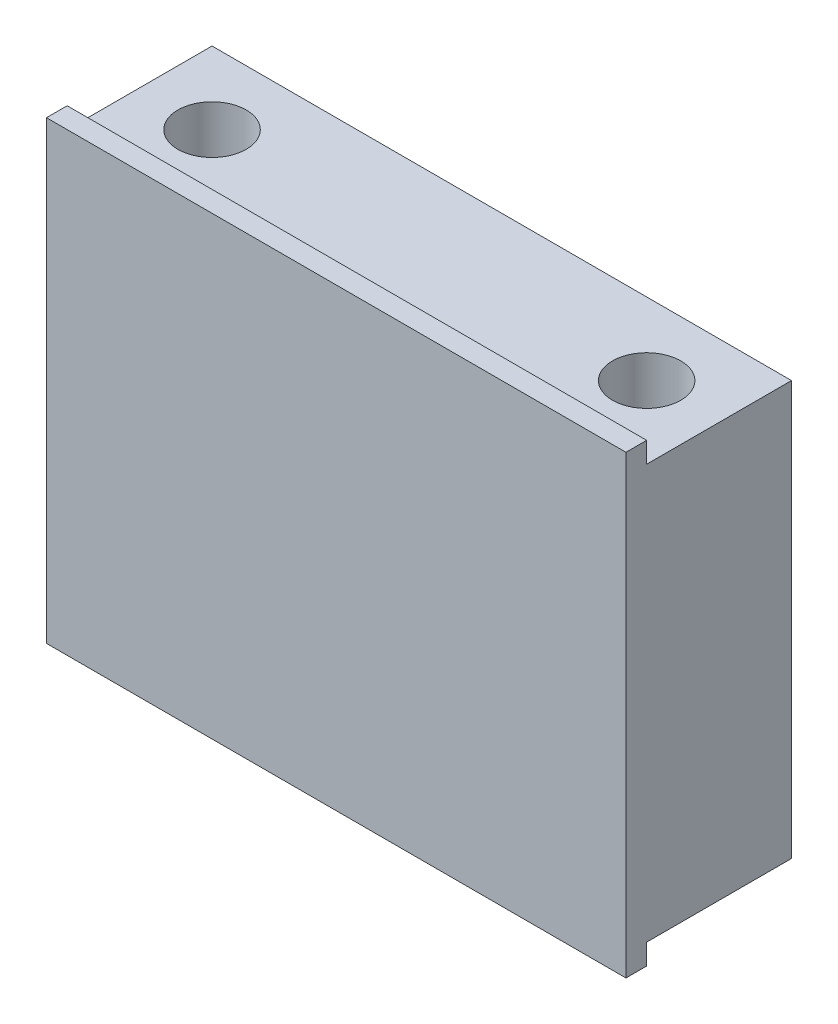
from build123d import *

# Parameters (mm, degrees)
SKETCH5_W                = 28
SKETCH5_H                = 20
BOSS_EXTRUDE2_DEPTH      = 4.5
BOSS_EXTRUDE2_DEPTH_BACK = 3.5
SKETCH9_W                = 28
SKETCH9_H                = 1
BOSS_EXTRUDE3_DEPTH      = 1
M4X0_7_TAPPED_HOLE2_D    = 3.3
CUT_EXTRUDE3_DEPTH       = 0.5


with BuildPart() as part:
    # Sketch5 → Boss-Extrude2 (new body, two sides)
    with BuildSketch(Plane.XY) as boss_extrude2_sk:
        Rectangle(SKETCH5_W, SKETCH5_H)
    extrude(amount=BOSS_EXTRUDE2_DEPTH)
    extrude(boss_extrude2_sk.sketch, amount=-BOSS_EXTRUDE2_DEPTH_BACK)

    # Sketch9 → Boss-Extrude3 (add)
    with BuildSketch(Plane(origin=(0, 10, 0), x_dir=(1, 0, 0), z_dir=(0, 1, 0))):
        with Locations((0, -4)):
            Rectangle(SKETCH9_W, SKETCH9_H)
    boss_extrude3 = extrude(amount=BOSS_EXTRUDE3_DEPTH)

    # Mirror2: Boss-Extrude3 across plane
    add(boss_extrude3.mirror(Plane.ZX))

    # M4x0.7 Tapped Hole2 (through all)
    with Locations(Plane(origin=(0, 10, 0), x_dir=(-1, 0, 0), z_dir=(0, 1, 0))):
        with Locations((10.5, 0), (-10.5, 0)):
            Hole(M4X0_7_TAPPED_HOLE2_D / 2)

    # Sketch18 → Cut-Extrude3 (cut)
    with BuildSketch(Plane.ZY.offset(14)):
        with BuildLine():
            Line((-1.358666808, -3.858598867), (-1.358666808, -3.175706239))
            add(Edge.make_bspline(
                [(-1.358666808, -3.175706239), (-1.358493825, -3.142277234), (-1.358158539, -3.077483501), (-1.352837806, -2.983271224), (-1.345764395, -2.894997594), (-1.333899128, -2.812818602), (-1.321596411, -2.736199521), (-1.303538968, -2.665918196), (-1.283593865, -2.601385933), (-1.252905616, -2.523895894), (-1.205246379, -2.435972827), (-1.134563201, -2.341471981), (-1.049819779, -2.25932608), (-0.953247965, -2.189477715), (-0.847008026, -2.133422916), (-0.733385749, -2.093382781), (-0.614292692, -2.067659474), (-0.53264339, -2.065047249), (-0.491379148, -2.063727072)],
                knots=[0, 0, 0, 0, 1.00128172, 1.940733171, 2.826250472, 3.653024905, 4.427672124, 5.149348099, 5.824709082, 6.450061444, 7.643590664, 8.808605388, 9.972104426, 11.165284501, 12.367876273, 13.557044126, 14.765369432, 16, 16, 16, 16], degree=3))
            add(Edge.make_bspline(
                [(-0.491379148, -2.063727072), (-0.452728292, -2.064826683), (-0.376775714, -2.066987522), (-0.265877874, -2.087398492), (-0.16042051, -2.119793619), (-0.060493879, -2.164564992), (0.032041876, -2.2222504), (0.116900105, -2.291365627), (0.190873633, -2.374407021), (0.232213446, -2.436655129), (0.253212198, -2.468274348)],
                knots=[0, 0, 0, 0, 1.044641374, 2.052818814, 3.038628718, 4.023282556, 5.005660861, 5.98021751, 6.974042014, 8, 8, 8, 8], degree=3))
            add(Edge.make_bspline(
                [(0.253212198, -2.468274348), (0.26848214, -2.42851776), (0.297697321, -2.352453558), (0.349268658, -2.247717736), (0.405563701, -2.157810249), (0.466090928, -2.0809748), (0.532295057, -2.015607722), (0.604713966, -1.958996053), (0.68328837, -1.910054162), (0.767729482, -1.868404951), (0.857321457, -1.835688977), (0.950970017, -1.811643189), (1.04831616, -1.797419583), (1.114377202, -1.795479265), (1.147843608, -1.794496303)],
                knots=[0, 0, 0, 0, 1.272586185, 2.434772614, 3.483318042, 4.437947805, 5.351807173, 6.25737843, 7.180033415, 8.1141739, 9.066731021, 10.025721652, 10.999834114, 12, 12, 12, 12], degree=3))
            add(Edge.make_bspline(
                [(1.147843608, -1.794496303), (1.18201062, -1.795472936), (1.249235171, -1.797394487), (1.34798832, -1.811577509), (1.442370565, -1.835575408), (1.532948895, -1.868687792), (1.619533397, -1.911606953), (1.701810406, -1.96459306), (1.779951098, -2.026902294), (1.854093382, -2.0973218), (1.921935902, -2.175798831), (1.98025759, -2.262285569), (2.03040593, -2.354412701), (2.07123492, -2.453357983), (2.102734459, -2.558868828), (2.124680974, -2.670886526), (2.139493315, -2.789226598), (2.140709493, -2.870436944), (2.141333192, -2.912084444)],
                knots=[0, 0, 0, 0, 0.978680899, 1.925582087, 2.851223405, 3.764209995, 4.683484765, 5.614004905, 6.562443559, 7.542772147, 8.539900013, 9.527881485, 10.525548727, 11.540192123, 12.58875426, 13.674701727, 14.807505862, 16, 16, 16, 16], degree=3))
            Line((2.141333192, -2.912084444), (2.141333192, -3.858598867))
            Line((2.141333192, -3.858598867), (-1.358666808, -3.858598867))
        make_face()
        with BuildLine():
            Line((-0.999692449, -3.544496303), (0.122102423, -3.544496303))
            Line((0.122102423, -3.544496303), (0.122102423, -3.333458643))
            add(Edge.make_bspline(
                [(0.122102423, -3.333458643), (0.1217025, -3.302609847), (0.120929767, -3.243003688), (0.118716249, -3.156683792), (0.112518208, -3.076558771), (0.106321937, -3.002766948), (0.096247378, -2.935424471), (0.084255162, -2.874680718), (0.07157256, -2.819581769), (0.050001794, -2.756043711), (0.018132793, -2.68396067), (-0.031373311, -2.607167438), (-0.090291826, -2.539153622), (-0.158911544, -2.48240852), (-0.233650484, -2.435556965), (-0.313852506, -2.402735978), (-0.39790365, -2.380855203), (-0.455716287, -2.37884849), (-0.485069052, -2.377829636)],
                knots=[0, 0, 0, 0, 1.156917035, 2.235399477, 3.236897345, 4.169954739, 5.01148057, 5.788325709, 6.491867502, 7.129259015, 8.302032419, 9.437271567, 10.542795419, 11.662606952, 12.764338259, 13.836858145, 14.901724648, 16, 16, 16, 16], degree=3))
            add(Edge.make_bspline(
                [(-0.485069052, -2.377829636), (-0.50449737, -2.378346947), (-0.542608137, -2.37936171), (-0.59834533, -2.387974533), (-0.650717848, -2.401929593), (-0.700228334, -2.420828506), (-0.745646335, -2.446647226), (-0.789142041, -2.476574514), (-0.82811027, -2.513524001), (-0.864427106, -2.555280202), (-0.896930553, -2.603056743), (-0.923854621, -2.65788297), (-0.948256772, -2.718341544), (-0.966320959, -2.786072736), (-0.982205579, -2.859673135), (-0.992185993, -2.940139316), (-0.998608484, -3.026961383), (-0.999323068, -3.087118171), (-0.999692449, -3.118214252)],
                knots=[0, 0, 0, 0, 0.911708768, 1.788416306, 2.640049961, 3.452993646, 4.268229297, 5.087074648, 5.92553149, 6.781184137, 7.681934069, 8.628939405, 9.643570426, 10.73771997, 11.914765019, 13.176320755, 14.540391495, 16, 16, 16, 16], degree=3))
            Line((-0.999692449, -3.118214252), (-0.999692449, -3.544496303))
        make_face(mode=Mode.SUBTRACT)
        with BuildLine():
            Line((0.481076782, -3.544496303), (1.782358833, -3.544496303))
            Line((1.782358833, -3.544496303), (1.782358833, -3.097180598))
            add(Edge.make_bspline(
                [(1.782358833, -3.097180598), (1.781936928, -3.065165021), (1.781123762, -3.003459217), (1.779216719, -2.914296476), (1.772002665, -2.831872051), (1.765347732, -2.755925921), (1.753968084, -2.686659648), (1.743228654, -2.623540432), (1.727286738, -2.567604418), (1.70537645, -2.502146341), (1.670300798, -2.42897934), (1.619055603, -2.349020978), (1.55581112, -2.279298526), (1.483882499, -2.21944831), (1.405889924, -2.170057312), (1.322852999, -2.134614599), (1.236386634, -2.112589233), (1.177417366, -2.109931667), (1.147843608, -2.108598867)],
                knots=[0, 0, 0, 0, 1.160376723, 2.23647316, 3.230273494, 4.158083346, 4.997711197, 5.773399541, 6.476071462, 7.102777513, 8.27340052, 9.405620712, 10.53304798, 11.669441455, 12.787990954, 13.865552736, 14.929550474, 16, 16, 16, 16], degree=3))
            add(Edge.make_bspline(
                [(1.147843608, -2.108598867), (1.12934987, -2.108874126), (1.092660698, -2.109420204), (1.038750685, -2.117693146), (0.986503358, -2.129661471), (0.935700993, -2.145424101), (0.887197765, -2.167459407), (0.840807664, -2.194472845), (0.795596176, -2.225394524), (0.73769895, -2.273100827), (0.671819937, -2.34350316), (0.608117034, -2.443552731), (0.555913121, -2.556684521), (0.533843542, -2.63892966), (0.522442967, -2.681415374)],
                knots=[0, 0, 0, 0, 0.723302347, 1.434937762, 2.129609326, 2.821140842, 3.513216847, 4.209993937, 4.920569932, 5.655069131, 7.14393391, 8.6716197, 10.280644748, 12, 12, 12, 12], degree=3))
            add(Edge.make_bspline(
                [(0.522442967, -2.681415374), (0.518987883, -2.698444469), (0.511496549, -2.735367062), (0.503588845, -2.795574642), (0.496543785, -2.864310511), (0.491332628, -2.941733388), (0.485946084, -3.027941229), (0.483851263, -3.123118148), (0.481352003, -3.226875463), (0.481170869, -3.298867835), (0.481076782, -3.33626313)],
                knots=[0, 0, 0, 0, 0.634451884, 1.375622551, 2.216452059, 3.157844607, 4.20941857, 5.370758133, 6.634282058, 8, 8, 8, 8], degree=3))
            Line((0.481076782, -3.33626313), (0.481076782, -3.544496303))
        make_face(mode=Mode.SUBTRACT)
        with BuildLine():
            add(Edge.make_bspline(
                [(-1.448410398, 0.561272928), (-1.446796552, 0.6260881), (-1.443626826, 0.753390445), (-1.418562039, 0.940311967), (-1.377308023, 1.119297706), (-1.319048544, 1.290450558), (-1.243522449, 1.453119587), (-1.151779874, 1.607764213), (-1.04326328, 1.753920982), (-0.919566131, 1.890583838), (-0.784097565, 2.015252023), (-0.639075896, 2.124649003), (-0.486324428, 2.216935679), (-0.325835196, 2.292482375), (-0.157982896, 2.351791539), (0.018173198, 2.392707704), (0.201479317, 2.418846641), (0.32650626, 2.42190231), (0.389930948, 2.423452415)],
                knots=[0, 0, 0, 0, 1.065064174, 2.09187391, 3.093564831, 4.079973196, 5.057907931, 6.036227367, 7.030399151, 8.044883615, 9.061699972, 10.052012555, 11.025713132, 11.989727027, 12.962874294, 13.945865945, 14.957962116, 16, 16, 16, 16], degree=3))
            add(Edge.make_bspline(
                [(0.389930948, 2.423452415), (0.452888068, 2.421901788), (0.576983845, 2.418845324), (0.759131968, 2.392686495), (0.934205486, 2.351608969), (1.101814183, 2.293216704), (1.261977455, 2.217612036), (1.414844561, 2.1251895), (1.560253583, 2.016000144), (1.696655417, 1.891861363), (1.821431514, 1.756134728), (1.931488892, 1.611670419), (2.023815742, 1.458923024), (2.100205848, 1.299475459), (2.158279017, 1.132075691), (2.200558202, 0.957941889), (2.226437652, 0.776125317), (2.229513436, 0.652270267), (2.231076782, 0.5893178)],
                knots=[0, 0, 0, 0, 1.043748596, 2.057349401, 3.045489418, 4.02252776, 4.995289225, 5.97782527, 6.980224157, 8.006516136, 9.032559198, 10.034193337, 11.013412982, 11.987833483, 12.961212594, 13.946489799, 14.956251404, 16, 16, 16, 16], degree=3))
            add(Edge.make_bspline(
                [(2.231076782, 0.5893178), (2.229527395, 0.525893481), (2.226473141, 0.400867265), (2.200291736, 0.217330229), (2.159350432, 0.041052485), (2.100840996, -0.127461866), (2.025223765, -0.288306795), (1.933019386, -0.441796878), (1.823612245, -0.587316025), (1.69944567, -0.723657772), (1.564274118, -0.84840697), (1.419439863, -0.957166346), (1.267784407, -1.049391459), (1.108886883, -1.124754792), (0.94351544, -1.184419251), (0.770566962, -1.225124069), (0.591027456, -1.251460021), (0.468784558, -1.254494868), (0.406757871, -1.256034765)],
                knots=[0, 0, 0, 0, 1.053102029, 2.075944431, 3.073151272, 4.055350789, 5.033113405, 6.020478099, 7.024410459, 8.052272461, 9.079885166, 10.07527673, 11.055994387, 12.023226415, 12.992069828, 13.970394897, 14.97016774, 16, 16, 16, 16], degree=3))
            add(Edge.make_bspline(
                [(0.406757871, -1.256034765), (0.365125202, -1.255500129), (0.282385079, -1.254437603), (0.159518478, -1.24164591), (0.038627821, -1.223084209), (-0.079943127, -1.196482297), (-0.195904112, -1.16169063), (-0.310054875, -1.120638602), (-0.421238599, -1.070498757), (-0.52998199, -1.013818109), (-0.634589896, -0.950556301), (-0.733469479, -0.880680551), (-0.827450476, -0.806645183), (-0.91409748, -0.725481789), (-0.995931136, -0.639865344), (-1.071693853, -0.548406966), (-1.142068804, -0.451664721), (-1.205489145, -0.349222342), (-1.26284828, -0.243604067), (-1.312070131, -0.134727289), (-1.354316192, -0.024070718), (-1.388557018, 0.08888393), (-1.415589054, 0.203836702), (-1.433996407, 0.321038487), (-1.446820725, 0.440395913), (-1.447878227, 0.520807232), (-1.448410398, 0.561272928)],
                knots=[0, 0, 0, 0, 1.037015668, 2.060948919, 3.074880161, 4.083647147, 5.086022904, 6.090072063, 7.104153813, 8.122640571, 9.144368836, 10.147691507, 11.138137339, 12.123020368, 13.103399296, 14.087645067, 15.080126199, 16.082011238, 17.087798457, 18.072939717, 19.057185487, 20.037253025, 21.01195951, 21.997135196, 22.992090687, 24, 24, 24, 24], degree=3))
        make_face()
        with BuildLine():
            add(Edge.make_bspline(
                [(-1.089436039, 0.576697607), (-1.089032561, 0.543482549), (-1.088229462, 0.477369971), (-1.077592868, 0.379091714), (-1.062541591, 0.282076135), (-1.04068186, 0.186510969), (-1.012407247, 0.092195801), (-0.978305832, -0.000911244), (-0.937089161, -0.09249093), (-0.890736007, -0.18242885), (-0.83808624, -0.268647733), (-0.782177329, -0.351355216), (-0.720931955, -0.428400011), (-0.655674645, -0.500840495), (-0.585839064, -0.568496518), (-0.511883831, -0.631338235), (-0.43348907, -0.689314116), (-0.350977409, -0.741726444), (-0.264809529, -0.788369326), (-0.176632587, -0.830130653), (-0.085410321, -0.864749199), (0.008288014, -0.892172246), (0.104049511, -0.915448129), (0.202395912, -0.930048486), (0.302988183, -0.940789883), (0.370970424, -0.941548496), (0.405355628, -0.9419322)],
                knots=[0, 0, 0, 0, 1.008406545, 2.007172654, 2.999155034, 3.989332444, 4.982025741, 5.988181096, 6.998684226, 8.030553839, 9.059268815, 10.065399129, 11.060956322, 12.046057109, 13.024974577, 14.012068307, 14.991706172, 15.984221787, 16.978487447, 17.966117052, 18.945677757, 19.938371053, 20.93015022, 21.936155317, 22.956113857, 24, 24, 24, 24], degree=3))
            add(Edge.make_bspline(
                [(0.405355628, -0.9419322), (0.455916699, -0.940654422), (0.555385968, -0.938140636), (0.701170513, -0.916224682), (0.841412037, -0.882197998), (0.975274647, -0.832865735), (1.10335527, -0.769932699), (1.225155465, -0.693167171), (1.340639302, -0.601866141), (1.448947118, -0.498217188), (1.547764598, -0.38487979), (1.634625682, -0.264589836), (1.707730393, -0.138299014), (1.768844288, -0.006735233), (1.814884954, 0.131224776), (1.847711928, 0.274696466), (1.868988023, 0.42368301), (1.871054437, 0.525208705), (1.872102423, 0.576697607)],
                knots=[0, 0, 0, 0, 1.032022337, 2.030307203, 3.003823408, 3.974715386, 4.937372378, 5.913284036, 6.909147208, 7.938749767, 8.970518239, 9.975863271, 10.963918693, 11.946286286, 12.933361397, 13.927862637, 14.949112547, 16, 16, 16, 16], degree=3))
            add(Edge.make_bspline(
                [(1.872102423, 0.576697607), (1.871627302, 0.611307245), (1.870684995, 0.679948552), (1.861180696, 0.782042078), (1.845969925, 0.88230578), (1.82396137, 0.980554404), (1.796781025, 1.076916678), (1.763066608, 1.171101842), (1.722651102, 1.263078613), (1.677609359, 1.353299262), (1.626443152, 1.439743661), (1.571287945, 1.52194946), (1.511123224, 1.598861519), (1.446742346, 1.671268015), (1.377121439, 1.738449883), (1.30361566, 1.801112677), (1.225054515, 1.858086139), (1.142880802, 1.910320788), (1.057341137, 1.957532784), (0.968921778, 1.998086153), (0.878096947, 2.032719569), (0.784799913, 2.060638026), (0.68924054, 2.082526201), (0.591282061, 2.097605385), (0.491122827, 2.108154022), (0.423378956, 2.108949073), (0.389229826, 2.109349851)],
                knots=[0, 0, 0, 0, 1.047334373, 2.07717862, 3.100662057, 4.115010574, 5.122652213, 6.129548646, 7.140165612, 8.16200981, 9.179904151, 10.178566626, 11.156366481, 12.133321541, 13.108841334, 14.082538371, 15.054589433, 16.043660176, 17.028268541, 18.009491307, 18.985652105, 19.968123554, 20.954864208, 21.950389976, 22.966808393, 24, 24, 24, 24], degree=3))
            add(Edge.make_bspline(
                [(0.389229826, 2.109349851), (0.355314322, 2.108948738), (0.288036672, 2.108153056), (0.188575854, 2.097610582), (0.091322642, 2.082509691), (-0.003341161, 2.060746983), (-0.095439687, 2.03269683), (-0.184886429, 1.998109496), (-0.272014645, 1.957324211), (-0.356608863, 1.910515933), (-0.437783895, 1.85790031), (-0.515385218, 1.800405324), (-0.587962027, 1.737042748), (-0.657281509, 1.669606354), (-0.721957132, 1.596474823), (-0.781739, 1.517635394), (-0.839320684, 1.435051065), (-0.890281113, 1.346854253), (-0.937578608, 1.256158484), (-0.977930631, 1.163008842), (-1.012587304, 1.06873564), (-1.040766265, 0.972961956), (-1.062457858, 0.87573306), (-1.077606337, 0.777105494), (-1.088225809, 0.677423526), (-1.089031349, 0.610379459), (-1.089436039, 0.576697607)],
                knots=[0, 0, 0, 0, 1.029877221, 2.042951179, 3.035109885, 4.018542222, 4.991021277, 5.957494829, 6.929429462, 7.911425532, 8.892163142, 9.866273635, 10.842761649, 11.81676864, 12.802607151, 13.805177466, 14.821356543, 15.858816981, 16.897175917, 17.927346774, 18.940346092, 19.946830556, 20.957962087, 21.964146003, 22.97721996, 24, 24, 24, 24], degree=3))
        make_face(mode=Mode.SUBTRACT)
        Polygon((-0.999692449, 2.737554979), (-1.358666808, 2.737554979), (-1.358666808, 4.577298569), (-0.999692449, 4.577298569), (-0.999692449, 3.814478056), (2.141333192, 3.814478056), (2.141333192, 3.500375492), (-0.999692449, 3.500375492), align=None)
    extrude(amount=-CUT_EXTRUDE3_DEPTH, mode=Mode.SUBTRACT)


solid = part.part
